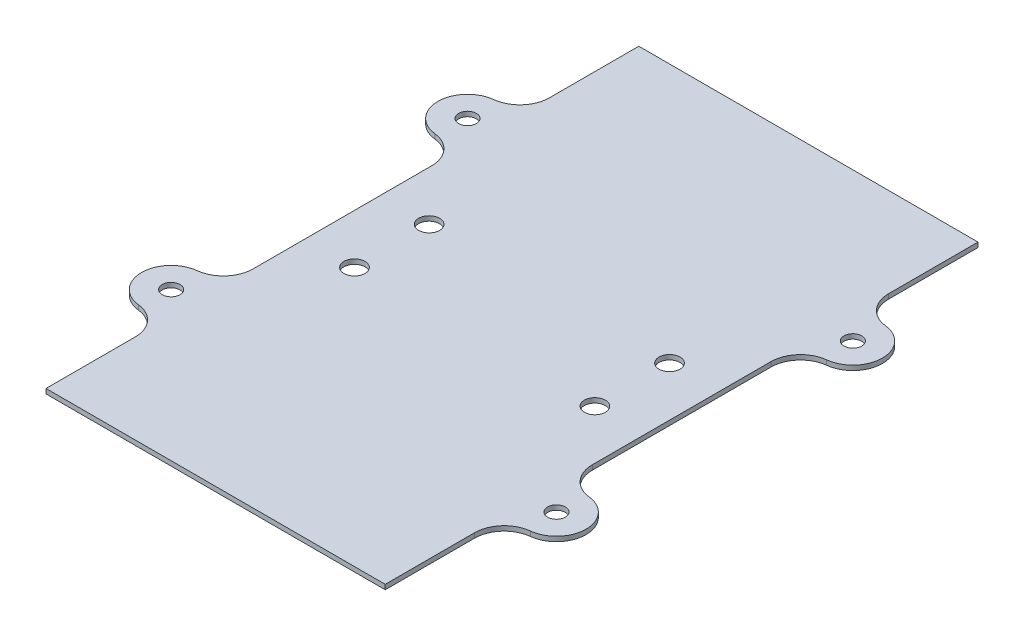
from build123d import *

# Parameters (mm, degrees)
SKETCH1_W             = 72.675
SKETCH1_H             = 127
BOSS_EXTRUDE1_DEPTH   = 1.016
SKETCH2_R             = 2.25
CUT_EXTRUDE1_DEPTH    = 2.016
BOSS_EXTRUDE2_DEPTH   = 1.016
F_6_CLEARANCE_HOLE1_D = 3.7973
FILLET1_R             = 6.35


with BuildPart() as part:
    # Sketch1 → Boss-Extrude1 (new body)
    with BuildSketch(Plane(origin=(0, 0, 0), x_dir=(1, 0, 0), z_dir=(0, 1, 0))):
        with Locations((-38.990743482, -0.569490469)):
            Rectangle(SKETCH1_W, SKETCH1_H)
    extrude(amount=BOSS_EXTRUDE1_DEPTH)

    # Sketch2 → Cut-Extrude1 (cut, through all)
    with BuildSketch(Plane.XZ):
        with Locations((-64.740743482, 8.569490469)):
            Circle(SKETCH2_R)
        with Locations((-64.740743482, -7.430509531)):
            Circle(SKETCH2_R)
        with Locations((-13.240743482, -7.430509531)):
            Circle(SKETCH2_R)
        with Locations((-13.240743482, 8.569490469)):
            Circle(SKETCH2_R)
    extrude(amount=-CUT_EXTRUDE1_DEPTH, mode=Mode.SUBTRACT)

    # Sketch3 → Boss-Extrude2 (add)
    with BuildSketch(Plane(origin=(0, 1.016, 0), x_dir=(1, 0, 0), z_dir=(0, 1, 0))):
        with BuildLine():
            Line((-80.265743482, 37.530509531), (-75.328243482, 37.530509531))
            Line((-75.328243482, 37.530509531), (-75.328243482, 24.830509531))
            Line((-75.328243482, 24.830509531), (-80.265743482, 24.830509531))
            ThreePointArc((-80.265743482, 24.830509531), (-86.615743482, 31.180509531), (-80.265743482, 37.530509531))
        make_face()
        with BuildLine():
            Line((2.284256518, 24.830509531), (-2.653243482, 24.830509531))
            Line((-2.653243482, 24.830509531), (-2.653243482, 37.530509531))
            Line((-2.653243482, 37.530509531), (2.284256518, 37.530509531))
            ThreePointArc((2.284256518, 37.530509531), (8.634256518, 31.180509531), (2.284256518, 24.830509531))
        make_face()
        with BuildLine():
            Line((-75.328243482, -38.669490469), (-75.328243482, -25.969490469))
            Line((-75.328243482, -25.969490469), (-80.265743482, -25.969490469))
            ThreePointArc((-80.265743482, -25.969490469), (-86.615743482, -32.319490469), (-80.265743482, -38.669490469))
            Line((-80.265743482, -38.669490469), (-75.328243482, -38.669490469))
        make_face()
        with BuildLine():
            Line((2.284256518, -25.969490469), (-2.653243482, -25.969490469))
            Line((-2.653243482, -25.969490469), (-2.653243482, -38.669490469))
            Line((-2.653243482, -38.669490469), (2.284256518, -38.669490469))
            ThreePointArc((2.284256518, -38.669490469), (8.634256518, -32.319490469), (2.284256518, -25.969490469))
        make_face()
    extrude(amount=-BOSS_EXTRUDE2_DEPTH)

    # #6 Clearance Hole1 (through all)
    with Locations(Plane(origin=(0, 1.016, 0), x_dir=(1, 0, 0), z_dir=(0, 1, 0))):
        with Locations((-80.265743482, 31.180509531), (-80.265743482, -32.319490469), (2.284256518, -32.319490469), (2.284256518, 31.180509531)):
            Hole(F_6_CLEARANCE_HOLE1_D / 2)

    # Fillet1
    fillet1_edges = [part.edges().sort_by_distance(p)[0] for p in [
        (-75.328243482, 0.508, -37.530509531),
        (-75.328243482, 0.508, -24.830509531),
        (-75.328243482, 0.508, 25.969490469),
        (-75.328243482, 0.508, 38.669490469),
        (-2.653243482, 0.508, -24.830509531),
        (-2.653243482, 0.508, -37.530509531),
        (-2.653243482, 0.508, 25.969490469),
        (-2.653243482, 0.508, 38.669490469),
    ]]
    fillet(fillet1_edges, radius=FILLET1_R)


solid = part.part
